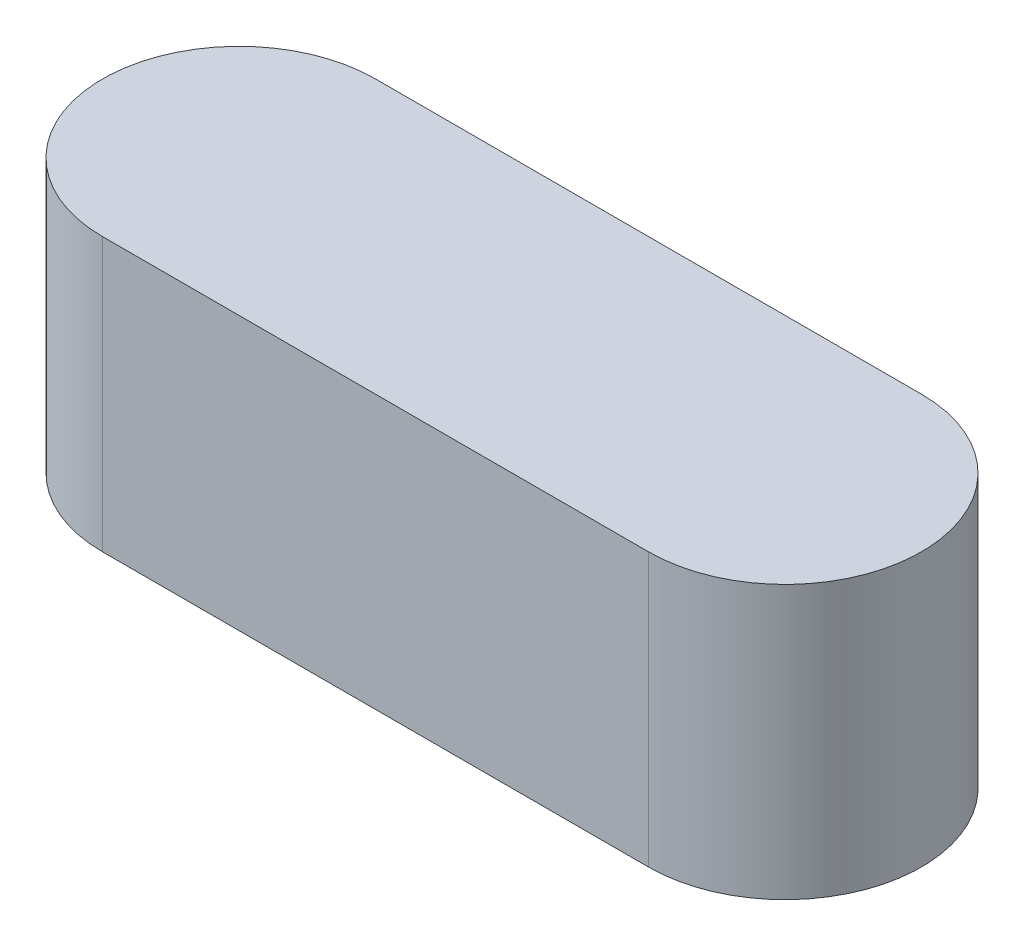
from build123d import *

# Parameters (mm, degrees)
BODY_DEPTH = 2


with BuildPart() as part:
    # Sketch4 → body (new body)
    with BuildSketch(Plane(origin=(0, 0, 0), x_dir=(1, 0, 0), z_dir=(0, 1, 0))):
        with BuildLine():
            Line((2, 1), (-2, 1))
            ThreePointArc((-2, 1), (-3, 0), (-2, -1))
            Line((-2, -1), (2, -1))
            ThreePointArc((2, -1), (3, 0), (2, 1))
        make_face()
    extrude(amount=BODY_DEPTH)


solid = part.part
